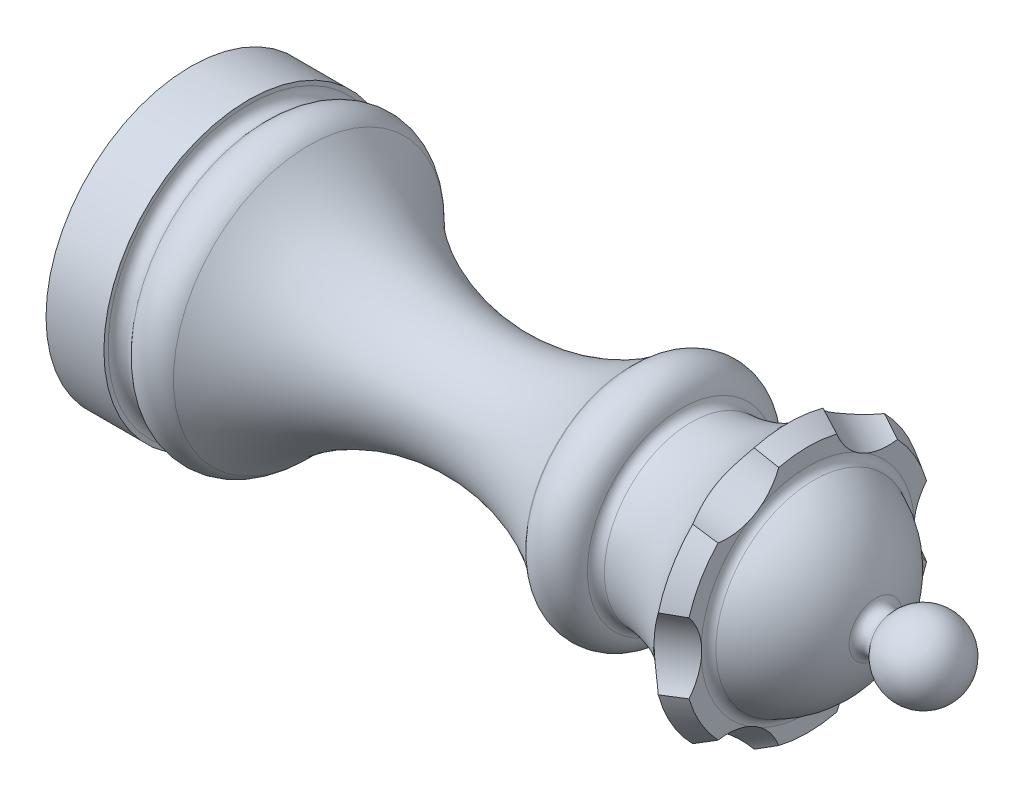
from build123d import *

# Parameters (mm, degrees)
CIRPATTERN1_COUNT = 6


with BuildPart() as part:
    # Sketch1 → Revolve1 (revolve)
    with BuildSketch(Plane.XY):
        with BuildLine():
            Line((0, 0), (0, -7.5))
            Line((0, -7.5), (3, -7.5))
            Line((3, -7.5), (3, -7.285575219))
            ThreePointArc((3, -7.285575219), (3.328989928, -6.815728909), (3.883022222, -6.964181415))
            ThreePointArc((3.883022222, -6.964181415), (4.993039611, -7.499491632), (6.129414318, -7.022681229))
            ThreePointArc((6.129414318, -7.022681229), (14.134456246, -3.06124342), (22.759910174, -5.379697715))
            ThreePointArc((22.759910174, -5.379697715), (22.808054917, -5.419102583), (22.850933335, -5.464181415))
            ThreePointArc((22.850933335, -5.464181415), (24.329229771, -5.963423301), (25.45128455, -4.879174305))
            ThreePointArc((25.45128455, -4.879174305), (25.638614467, -4.602914147), (25.958048738, -4.506095144))
            ThreePointArc((25.958048738, -4.506095144), (28.740452901, -5.224515013), (31, -7))
            Line((31, -7), (32, -6.422649731))
            Line((32, -6.422649731), (32, -5.537718405))
            ThreePointArc((32, -5.537718405), (32.083930219, -5.26043527), (32.307543748, -5.076241871))
            ThreePointArc((32.307543748, -5.076241871), (34.346486829, -3.602496511), (35.515877082, -1.375))
            ThreePointArc((35.515877082, -1.375), (35.902915417, -1.00951597), (36.4, -1.2))
            ThreePointArc((36.4, -1.2), (38.632455532, -1.897366596), (40, 0))
            Line((40, 0), (0, 0))
        make_face()
    revolve(axis=Axis((0, 0, 0), (-1, 0, 0)))

    # Sketch2 → Cut-Revolve1 (revolve, cut)
    with BuildSketch(Plane(origin=(0, 0, 0), x_dir=(1, 0, 0), z_dir=(0, 1, 0))):
        with BuildLine():
            Line((30.435381148, -6.402222415), (32, -5.4988893))
            ThreePointArc((32, -5.4988893), (34.409250468, -5.181705459), (36.337130657, -6.661019957))
            Line((36.337130657, -6.661019957), (29.273250491, -10.739353072))
            ThreePointArc((29.273250491, -10.739353072), (28.95606665, -8.330102604), (30.435381148, -6.402222415))
        make_face()
    cut_revolve1 = revolve(axis=Axis((29.581143931, 0, 10.561590712), (-0.8660254037844308, 0, 0.5000000000000135)), mode=Mode.SUBTRACT)

    # CirPattern1: Cut-Revolve1 ×6 about axis
    cirpattern1_axis = Axis((0, 0, 0), (1, 0, 0))
    for i in range(1, CIRPATTERN1_COUNT):
        add(cut_revolve1.rotate(cirpattern1_axis, i * 360 / CIRPATTERN1_COUNT), mode=Mode.SUBTRACT)


solid = part.part
